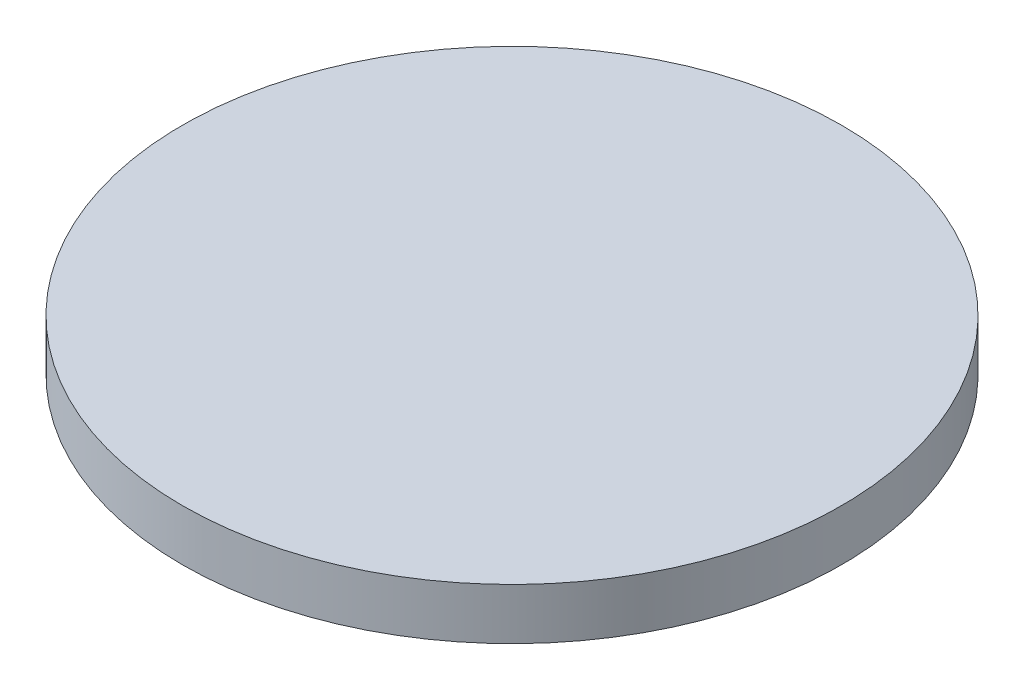
from build123d import *

# Parameters (mm, degrees)
SKETCH1_R           = 114.3
BOSS_EXTRUDE1_DEPTH = 17.78


with BuildPart() as part:
    # Sketch1 → Boss-Extrude1 (new body)
    with BuildSketch(Plane(origin=(0, 0, 0), x_dir=(1, 0, 0), z_dir=(0, 1, 0))):
        Circle(SKETCH1_R)
    extrude(amount=BOSS_EXTRUDE1_DEPTH)


solid = part.part
